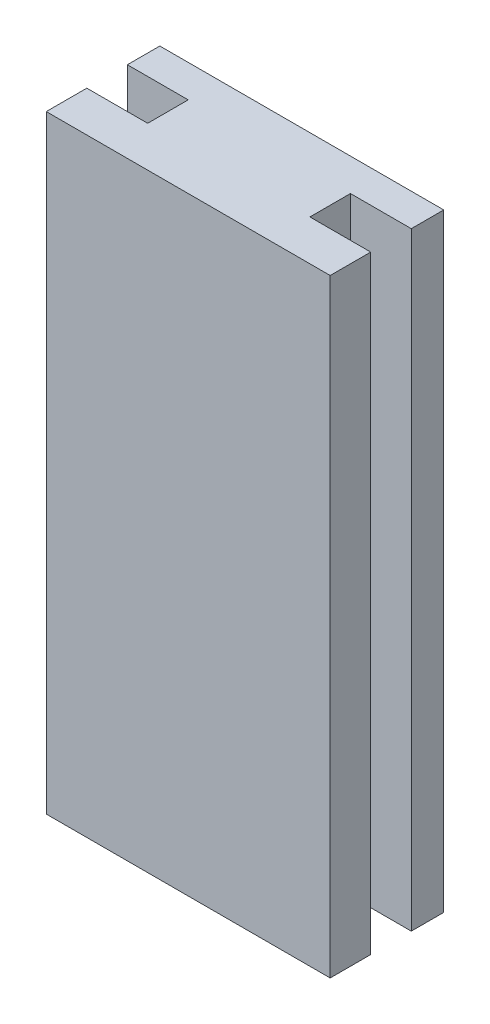
from build123d import *

# Parameters (mm, degrees)
EXTRUDE_1_DEPTH = 150


with BuildPart() as part:
    # 草图2 → 凸台-拉伸1 (new body)
    with BuildSketch(Plane(origin=(0, 0, 0), x_dir=(1, 0, 0), z_dir=(0, 1, 0))):
        Polygon((0, 0), (70, 0), (70, 10), (55, 10), (55, 20), (70, 20), (70, 28), (0, 28), (0, 20), (15, 20), (15, 10), (0, 10), align=None)
    extrude(amount=EXTRUDE_1_DEPTH)


solid = part.part
